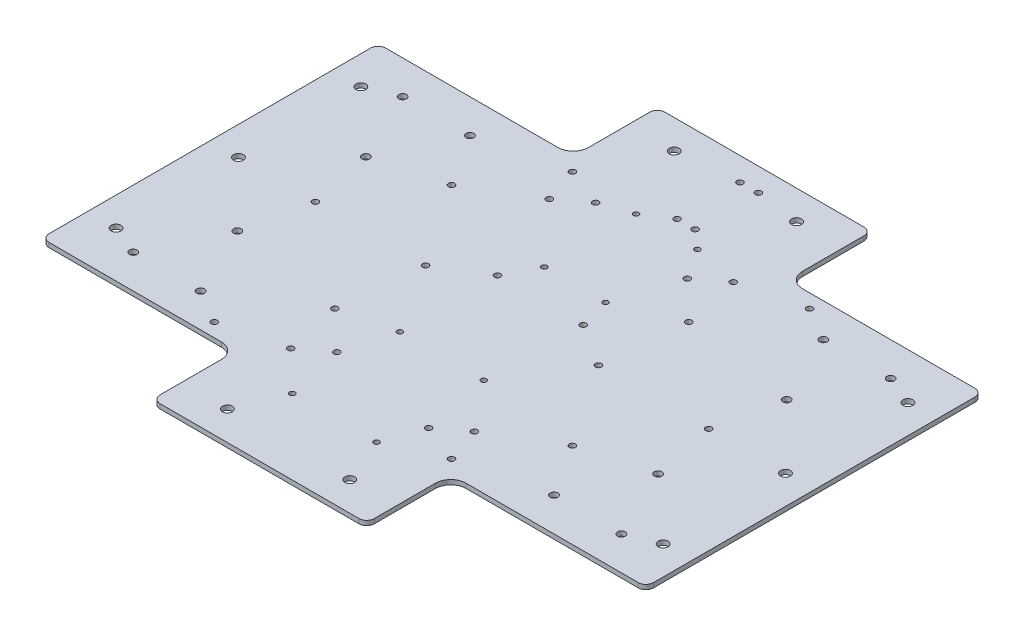
from build123d import *

# Parameters (mm, degrees)
SKETCH_1_R          = 3.2
SKETCH_1_R_2        = 2.5
EXTRUDE_1_DEPTH     = 3
SKETCH_2_R          = 2
SKETCH_2_R_2        = 1.75
CUT_EXTRUDE_1_DEPTH = 10


with BuildPart() as part:
    # Эскиз1 → Бобышка-Вытянуть1 (new body)
    with BuildSketch(Plane(origin=(0, 0, 0), x_dir=(1, 0, 0), z_dir=(0, 1, 0))):
        with BuildLine():
            Line((-65, -165), (65, -165))
            ThreePointArc((65, -165), (68.535533906, -163.535533906), (70, -160))
            Line((70, -160), (70, -120))
            ThreePointArc((70, -120), (72.928932188, -112.928932188), (80, -110))
            Line((80, -110), (192.5, -110))
            ThreePointArc((192.5, -110), (196.035533906, -108.535533906), (197.5, -105))
            Line((197.5, -105), (197.5, 105))
            ThreePointArc((197.5, 105), (196.035533906, 108.535533906), (192.5, 110))
            Line((192.5, 110), (80, 110))
            ThreePointArc((80, 110), (72.928932188, 112.928932188), (70, 120))
            Line((70, 120), (70, 160))
            ThreePointArc((70, 160), (68.535533906, 163.535533906), (65, 165))
            Line((65, 165), (-65, 165))
            ThreePointArc((-65, 165), (-68.535533906, 163.535533906), (-70, 160))
            Line((-70, 160), (-70, 120))
            ThreePointArc((-70, 120), (-72.928932188, 112.928932188), (-80, 110))
            Line((-80, 110), (-192.5, 110))
            ThreePointArc((-192.5, 110), (-196.035533906, 108.535533906), (-197.5, 105))
            Line((-197.5, 105), (-197.5, -105))
            ThreePointArc((-197.5, -105), (-196.035533906, -108.535533906), (-192.5, -110))
            Line((-192.5, -110), (-80, -110))
            ThreePointArc((-80, -110), (-72.928932188, -112.928932188), (-70, -120))
            Line((-70, -120), (-70, -160))
            ThreePointArc((-70, -160), (-68.535533906, -163.535533906), (-65, -165))
        make_face()
        with Locations((40, 146)):
            Circle(SKETCH_1_R, mode=Mode.SUBTRACT)
        with Locations((40, -146)):
            Circle(SKETCH_1_R, mode=Mode.SUBTRACT)
        with Locations((-40, -146)):
            Circle(SKETCH_1_R, mode=Mode.SUBTRACT)
        with Locations((-40, 146)):
            Circle(SKETCH_1_R, mode=Mode.SUBTRACT)
        with Locations((-178.768667216, 80)):
            Circle(SKETCH_1_R, mode=Mode.SUBTRACT)
        with Locations((-178.768667216, -80)):
            Circle(SKETCH_1_R, mode=Mode.SUBTRACT)
        with Locations((-178.768667216, 0)):
            Circle(SKETCH_1_R, mode=Mode.SUBTRACT)
        with Locations((178.768667216, 80)):
            Circle(SKETCH_1_R, mode=Mode.SUBTRACT)
        with Locations((178.768667216, 0)):
            Circle(SKETCH_1_R, mode=Mode.SUBTRACT)
        with Locations((178.768667216, -80)):
            Circle(SKETCH_1_R, mode=Mode.SUBTRACT)
        with Locations((137.5, -42)):
            Circle(SKETCH_1_R_2, mode=Mode.SUBTRACT)
        with Locations((159.5, -88)):
            Circle(SKETCH_1_R_2, mode=Mode.SUBTRACT)
        with Locations((115.5, -88)):
            Circle(SKETCH_1_R_2, mode=Mode.SUBTRACT)
        with Locations((-159.5, -88)):
            Circle(SKETCH_1_R_2, mode=Mode.SUBTRACT)
        with Locations((-137.5, -42)):
            Circle(SKETCH_1_R_2, mode=Mode.SUBTRACT)
        with Locations((-115.5, -88)):
            Circle(SKETCH_1_R_2, mode=Mode.SUBTRACT)
        with Locations((159.5, 88)):
            Circle(SKETCH_1_R_2, mode=Mode.SUBTRACT)
        with Locations((137.5, 42)):
            Circle(SKETCH_1_R_2, mode=Mode.SUBTRACT)
        with Locations((115.5, 88)):
            Circle(SKETCH_1_R_2, mode=Mode.SUBTRACT)
        with Locations((-115.5, 88)):
            Circle(SKETCH_1_R_2, mode=Mode.SUBTRACT)
        with Locations((-137.5, 42)):
            Circle(SKETCH_1_R_2, mode=Mode.SUBTRACT)
        with Locations((-159.5, 88)):
            Circle(SKETCH_1_R_2, mode=Mode.SUBTRACT)
    extrude(amount=EXTRUDE_1_DEPTH)

    # Эскиз2 → Вырез-Вытянуть1 (cut)
    with BuildSketch(Plane(origin=(0, 3, 0), x_dir=(1, 0, 0), z_dir=(0, 1, 0))):
        with Locations((128.5, 0)):
            Circle(SKETCH_2_R)
        with Locations((56.5, 0)):
            Circle(SKETCH_2_R)
        with Locations((93.5, 101)):
            Circle(SKETCH_2_R)
        with Locations((61.5, 54)):
            Circle(SKETCH_2_R)
        with Locations((53.5, 91.092247848)):
            Circle(SKETCH_2_R)
        with Locations((36.502982491, 78.046799413)):
            Circle(SKETCH_2_R)
        with Locations((28.680928288, 17.871923503)):
            Circle(SKETCH_2_R)
        with Locations((-27.319071712, 17.871923503)):
            Circle(SKETCH_2_R)
        with Locations((27.496289721, -46.022287392)):
            Circle(SKETCH_2_R_2)
        with Locations((93.5, -54.053341302)):
            Circle(SKETCH_2_R)
        with Locations((61.5, -101.042998556)):
            Circle(SKETCH_2_R)
        with Locations((53.5, -78.07249598)):
            Circle(SKETCH_2_R)
        with Locations((36.502982491, -90.999139468)):
            Circle(SKETCH_2_R)
        with Locations((27.496289721, -116.033195429)):
            Circle(SKETCH_2_R_2)
        with Locations((-27.552622159, -116.033195429)):
            Circle(SKETCH_2_R_2)
        with Locations((-27.319071712, -46)):
            Circle(SKETCH_2_R_2)
        with Locations((-53.636340651, -90.999139468)):
            Circle(SKETCH_2_R)
        with Locations((-36.401722668, -78.07249598)):
            Circle(SKETCH_2_R)
        with Locations((-93.526794479, -101.042998556)):
            Circle(SKETCH_2_R)
        with Locations((-61.727710595, -54.053341302)):
            Circle(SKETCH_2_R)
        with Locations((-36.401722668, 91.092247848)):
            Circle(SKETCH_2_R)
        with Locations((-53.636340651, 78.046799413)):
            Circle(SKETCH_2_R)
        with Locations((-61.541675198, 101)):
            Circle(SKETCH_2_R)
        with Locations((-93.526794479, 54)):
            Circle(SKETCH_2_R)
        with Locations((-128.5, 0)):
            Circle(SKETCH_2_R)
        with Locations((-56.5, 0)):
            Circle(SKETCH_2_R)
        with Locations((-16.832308482, 37.872518528)):
            Circle(SKETCH_2_R_2)
        with Locations((-16.797794126, 97.927570988)):
            Circle(SKETCH_2_R_2)
        with Locations((23.276008527, 97.927570988)):
            Circle(SKETCH_2_R_2)
        with Locations((23.276008527, 37.872518528)):
            Circle(SKETCH_2_R_2)
        with Locations((-0.75963633, 149.730797231)):
            Circle(SKETCH_2_R)
        with Locations((11.137406716, 149.864440097)):
            Circle(SKETCH_2_R)
        with Locations((11.137406716, 108.512875125)):
            Circle(SKETCH_2_R)
        with Locations((-0.627896327, 108.512875125)):
            Circle(SKETCH_2_R)
    extrude(amount=-CUT_EXTRUDE_1_DEPTH, mode=Mode.SUBTRACT)


solid = part.part
